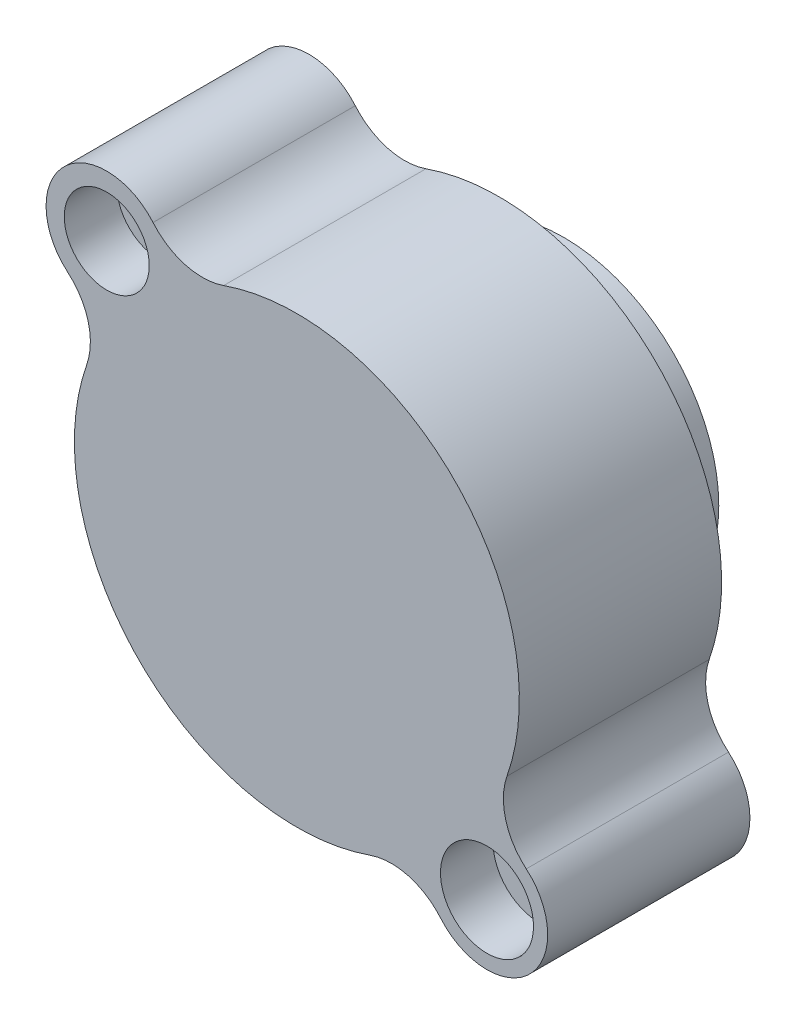
from build123d import *

# Parameters (mm, degrees)
BOSS_EXTRU_1_DEPTH   = 635
ESQUISSE2_R          = 486.41
BOSS_EXTRU_2_DEPTH   = 203.2
PER_AGE1_D           = 139.7
PER_AGE1_DEPTH       = 838.2
PER_AGE1_CBORE_D     = 266.7
PER_AGE1_CBORE_DEPTH = 165.1
PER_AGE2_D           = 139.7
PER_AGE2_DEPTH       = 838.2
PER_AGE2_CBORE_D     = 292.1
PER_AGE2_CBORE_DEPTH = 165.1


with BuildPart() as part:
    # Esquisse1 → Boss.-Extru.1 (new body)
    with BuildSketch(Plane.XY.offset(838.2)):
        with BuildLine():
            ThreePointArc((-720.101782381, 451.601786597), (-655.471932336, 350.063866609), (-659.625858178, 229.773752251))
            ThreePointArc((-659.625858178, 229.773752251), (-493.914086659, -493.914086659), (229.773752251, -659.625858178))
            ThreePointArc((229.773752251, -659.625858178), (350.063866609, -655.471932336), (451.601786597, -720.101782381))
            ThreePointArc((451.601786597, -720.101782381), (731.603841816, -731.603841816), (720.101782381, -451.601786597))
            ThreePointArc((720.101782381, -451.601786597), (655.471932336, -350.063866609), (659.625858178, -229.773752251))
            ThreePointArc((659.625858178, -229.773752251), (493.914086659, 493.914086659), (-229.773752251, 659.625858178))
            ThreePointArc((-229.773752251, 659.625858178), (-350.063866609, 655.471932336), (-451.601786597, 720.101782381))
            ThreePointArc((-451.601786597, 720.101782381), (-731.603841816, 731.603841816), (-720.101782381, 451.601786597))
        make_face()
    extrude(amount=-BOSS_EXTRU_1_DEPTH)

    # Esquisse2 → Boss.-Extru.2 (add)
    with BuildSketch(Plane(origin=(0, 0, 203.2), x_dir=(-1, 0, 0), z_dir=(0, 0, -1))):
        Circle(ESQUISSE2_R)
    extrude(amount=BOSS_EXTRU_2_DEPTH)

    # Perçage1
    with Locations(Plane.XY.offset(838.2)):
        with Locations((-596.9, 596.9)):
            CounterBoreHole(PER_AGE1_D / 2, PER_AGE1_CBORE_D / 2, PER_AGE1_CBORE_DEPTH, depth=PER_AGE1_DEPTH)

    # Perçage2
    with Locations(Plane.XY.offset(838.2)):
        with Locations((596.9, -596.9)):
            CounterBoreHole(PER_AGE2_D / 2, PER_AGE2_CBORE_D / 2, PER_AGE2_CBORE_DEPTH, depth=PER_AGE2_DEPTH)


solid = part.part
